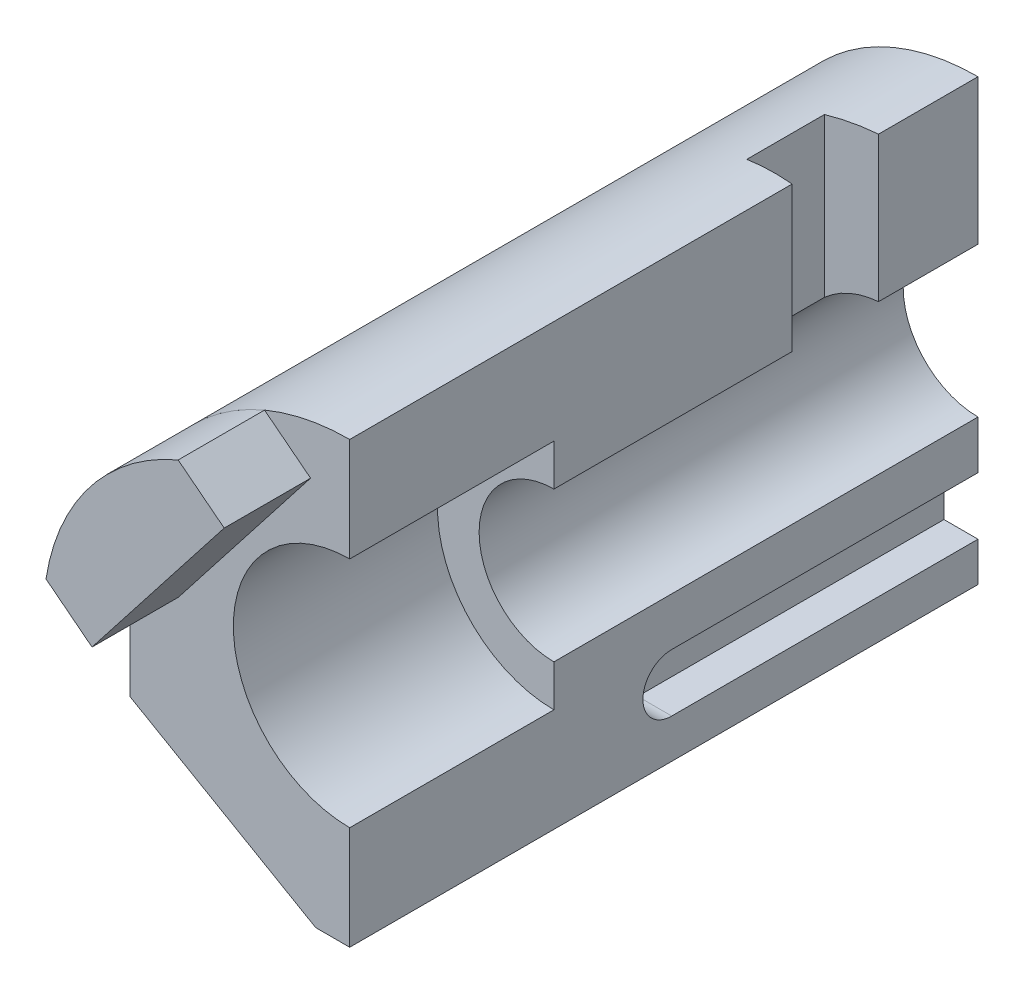
from build123d import *

# Parameters (mm, degrees)
BOSS_EXTRUDE1_DEPTH = 33
BOSS_EXTRUDE2_DEPTH = 240
BOSS_EXTRUDE3_START = -78
BOSS_EXTRUDE3_DEPTH = 162
CUT_EXTRUDE1_DEPTH  = 13
CUT_EXTRUDE2_START  = -62.656837
CUT_EXTRUDE2_DEPTH  = 62.656837


with BuildPart() as part:
    # Sketch1 → Boss-Extrude1 (new body)
    with BuildSketch(Plane.XY):
        with BuildLine():
            ThreePointArc((-32.530408402, 161.445287327), (-66.192903303, 135.715563927), (-83.014649379, 96.828405531))
            Line((-83.014649379, 96.828405531), (-65.430668922, 83.090294344))
            Line((-65.430668922, 83.090294344), (-14.946427946, 147.707176139))
            Line((-14.946427946, 147.707176139), (-32.530408402, 161.445287327))
        make_face()
    extrude(amount=BOSS_EXTRUDE1_DEPTH)


with BuildPart() as body_2:
    # Sketch1_4 → Boss-Extrude2 (new body)
    with BuildSketch(Plane.XY):
        with BuildLine():
            Line((-13, 0), (0, 0))
            Line((0, 0), (0, 39.55))
            ThreePointArc((0, 39.55), (-44.45, 84), (0, 128.45))
            Line((0, 128.45), (0, 168))
            ThreePointArc((0, 168), (-59.39696962, 143.39696962), (-84, 84))
            Line((-84, 84), (-84, 40.991869112))
            Line((-84, 40.991869112), (-13, 0))
        make_face()
    extrude(amount=-BOSS_EXTRUDE2_DEPTH)

    # Sketch1_5 → Boss-Extrude3 (add)
    with BuildSketch(Plane.XY.offset(BOSS_EXTRUDE3_START)):
        with BuildLine():
            Line((0, 0), (-13, 0))
            Line((-13, 0), (-84, 40.991869112))
            Line((-84, 40.991869112), (-84, 84))
            ThreePointArc((-84, 84), (-59.39696962, 143.39696962), (0, 168))
            Line((0, 168), (0, 112.575))
            ThreePointArc((0, 112.575), (-28.575, 84), (0, 55.425))
            Line((0, 55.425), (0, 0))
        make_face()
    extrude(amount=-BOSS_EXTRUDE3_DEPTH)

    # Sketch2 → Cut-Extrude1 (cut)
    with BuildSketch(Plane(origin=(0, 0, 0), x_dir=(0, 0, -1), z_dir=(1, 0, 0))):
        with BuildLine():
            Line((240, 37), (123, 37))
            ThreePointArc((123, 37), (112, 26), (123, 15))
            Line((123, 15), (240, 15))
            Line((240, 15), (240, 37))
        make_face()
    extrude(amount=-CUT_EXTRUDE1_DEPTH, mode=Mode.SUBTRACT)

    # Sketch3 → Cut-Extrude2 (cut)
    with BuildSketch(Plane(origin=(0, 168, 0), x_dir=(1, 0, 0), z_dir=(0, 1, 0)).offset(CUT_EXTRUDE2_START)):
        Polygon((0, 169), (-19, 170.662284607), (-19, 200.337715393), (0, 202), align=None)
    extrude(amount=CUT_EXTRUDE2_DEPTH, mode=Mode.SUBTRACT)


solid = Compound([part.part, body_2.part])
